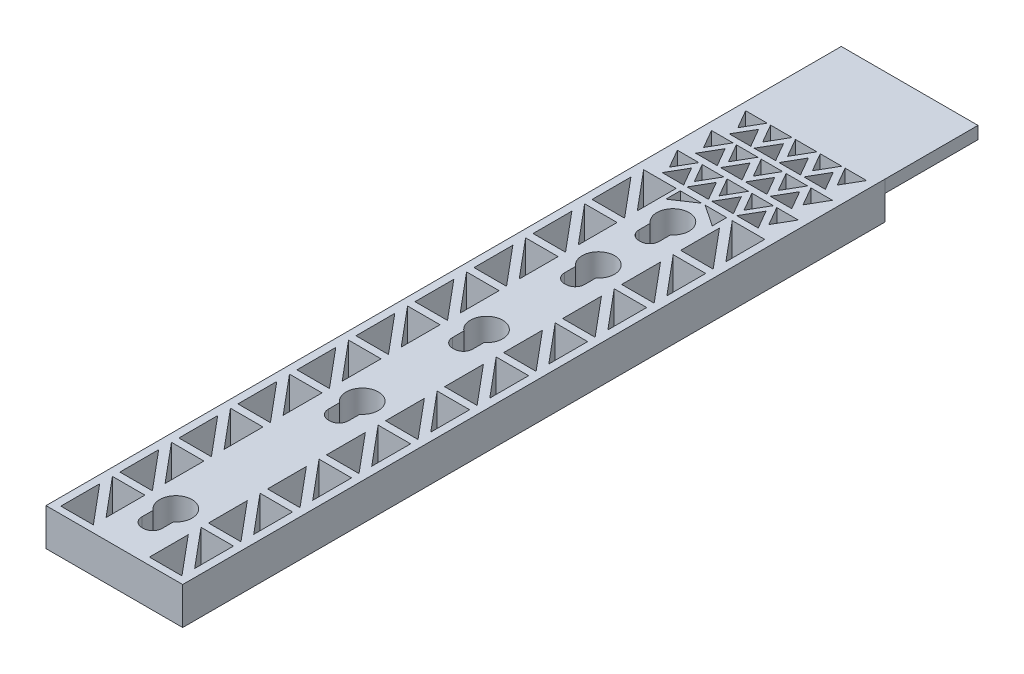
from build123d import *

# Parameters (mm, degrees)
SKETCH23_W             = 22
SKETCH23_H             = 113
SKETCH23_R             = 2.6
BOSS_EXTRUDE3_DEPTH    = 6
SKETCH25_W             = 3.25
SKETCH25_H             = 5.5
CUT_EXTRUDE1_DEPTH     = 15.321988807
FILLET1_R              = 1.5
FILLET2_R              = 1.5
CUT_EXTRUDE7_DEPTH     = 13.794769433
LPATTERN3_COUNT        = 3
LPATTERN3_PITCH        = 4
LPATTERN3_COL_COUNT    = 3
LPATTERN3_COL_PITCH    = 4
LPATTERN4_COUNT        = 3
LPATTERN4_PITCH        = 5.5
LPATTERN4_COPY_1_DEPTH = 13.794769433
LPATTERN4_COPY_2_DEPTH = 13.794769433
LPATTERN4_COPY_3_DEPTH = 13.794769433
LPATTERN4_COPY_4_DEPTH = 13.794769433
LPATTERN4_COPY_5_DEPTH = 13.794769433
LPATTERN4_COPY_6_DEPTH = 13.794769433
LPATTERN4_COPY_7_DEPTH = 13.794769433
LPATTERN4_COPY_8_DEPTH = 13.794769433
CUT_EXTRUDE8_DEPTH     = 13.484872428
LPATTERN5_COUNT        = 4
LPATTERN5_PITCH        = 4
LPATTERN5_COUNT_DIR2   = 3
LPATTERN5_PITCH_DIR2   = 5.4
CUT_EXTRUDE9_DEPTH     = 53.672312212
LPATTERN7_COUNT        = 10
LPATTERN7_PITCH        = 9.5
CUT_EXTRUDE10_DEPTH    = 24.803748702
LPATTERN8_COUNT        = 10
LPATTERN8_PITCH        = 9.5
CUT_EXTRUDE11_DEPTH    = 27.40661391
LPATTERN9_COUNT        = 10
LPATTERN9_PITCH        = 9.5
CUT_EXTRUDE12_DEPTH    = 18.752181215
LPATTERN10_COUNT       = 10
LPATTERN10_PITCH       = 9.5
CUT_EXTRUDE13_DEPTH    = 6
SKETCH42_W             = 22.003595265
SKETCH42_H             = 15
BOSS_EXTRUDE4_DEPTH    = 2
BOSS_EXTRUDE5_DEPTH    = 4


with BuildPart() as part:
    # Sketch23 → Boss-Extrude3 (new body)
    with BuildSketch(Plane(origin=(0, 0, 0), x_dir=(1, 0, 0), z_dir=(0, 1, 0))):
        with Locations((192.096404735, -56.5)):
            Rectangle(SKETCH23_W, SKETCH23_H)
        with Locations((192, -73)):
            Circle(SKETCH23_R, mode=Mode.SUBTRACT)
        with Locations((192, -53)):
            Circle(SKETCH23_R, mode=Mode.SUBTRACT)
        with Locations((192, -35)):
            Circle(SKETCH23_R, mode=Mode.SUBTRACT)
        with Locations((192, -23)):
            Circle(SKETCH23_R, mode=Mode.SUBTRACT)
        with Locations((192, -103)):
            Circle(SKETCH23_R, mode=Mode.SUBTRACT)
    extrude(amount=-BOSS_EXTRUDE3_DEPTH)

    # Sketch25 → Cut-Extrude1 (cut)
    with BuildSketch(Plane(origin=(0, 0, 0), x_dir=(1, 0, 0), z_dir=(0, 1, 0))):
        with Locations((192, -105.6)):
            Rectangle(SKETCH25_W, SKETCH25_H)
        with Locations((192, -75.6)):
            Rectangle(SKETCH25_W, SKETCH25_H)
        with Locations((192, -55.6)):
            Rectangle(SKETCH25_W, SKETCH25_H)
        with Locations((192, -37.6)):
            Rectangle(SKETCH25_W, SKETCH25_H)
        with Locations((192, -25.6)):
            Rectangle(SKETCH25_W, SKETCH25_H)
    extrude(amount=-CUT_EXTRUDE1_DEPTH, mode=Mode.SUBTRACT)

    # Fillet1
    fillet1_edges = [part.edges().sort_by_distance(p)[0] for p in [
        (193.625, -3, 108.35),
        (190.375, -3, 108.35),
        (193.625, -3, 78.35),
        (190.375, -3, 78.35),
        (193.625, -3, 40.35),
        (190.375, -3, 40.35),
        (193.625, -3, 28.35),
        (190.375, -3, 28.35),
    ]]
    fillet(fillet1_edges, radius=FILLET1_R)

    # Fillet2
    fillet2_edges = [part.edges().sort_by_distance(p)[0] for p in [
        (193.625, -3, 58.35),
        (190.375, -3, 58.35),
    ]]
    fillet(fillet2_edges, radius=FILLET2_R)

    # Sketch30 → Cut-Extrude7 (cut)
    with BuildSketch(Plane(origin=(0, 0, 0), x_dir=(1, 0, 0), z_dir=(0, 1, 0))):
        Polygon((192.096404735, -4.654849334), (193.828455542, -1.654849334), (190.364353927, -1.654849334), align=None)
    cut_extrude7 = extrude(amount=-CUT_EXTRUDE7_DEPTH, mode=Mode.SUBTRACT)

    # LPattern3: Cut-Extrude7 ×3
    with Locations(*[(-i * LPATTERN3_PITCH, 0, 0) for i in range(1, LPATTERN3_COUNT)]):
        add(cut_extrude7, mode=Mode.SUBTRACT)

    # LPattern3 col: Cut-Extrude7 ×3
    with Locations(*[(i * LPATTERN3_COL_PITCH, 0, 0) for i in range(1, LPATTERN3_COL_COUNT)]):
        add(cut_extrude7, mode=Mode.SUBTRACT)

    # LPattern4: Cut-Extrude7 ×3
    with Locations(*[(0, 0, i * LPATTERN4_PITCH) for i in range(1, LPATTERN4_COUNT)]):
        add(cut_extrude7, mode=Mode.SUBTRACT)

    # LPattern4 copy 1 sketch → LPattern4 copy 1 (cut)
    with BuildSketch(Plane(origin=(-4, 0, 5.5), x_dir=(1, 0, 0), z_dir=(0, 1, 0))):
        Polygon((192.096404735, -4.654849334), (193.828455542, -1.654849334), (190.364353927, -1.654849334), align=None)
    extrude(amount=-LPATTERN4_COPY_1_DEPTH, mode=Mode.SUBTRACT)

    # LPattern4 copy 2 sketch → LPattern4 copy 2 (cut)
    with BuildSketch(Plane(origin=(-4, 0, 11), x_dir=(1, 0, 0), z_dir=(0, 1, 0))):
        Polygon((192.096404735, -4.654849334), (193.828455542, -1.654849334), (190.364353927, -1.654849334), align=None)
    extrude(amount=-LPATTERN4_COPY_2_DEPTH, mode=Mode.SUBTRACT)

    # LPattern4 copy 3 sketch → LPattern4 copy 3 (cut)
    with BuildSketch(Plane(origin=(-8, 0, 5.5), x_dir=(1, 0, 0), z_dir=(0, 1, 0))):
        Polygon((192.096404735, -4.654849334), (193.828455542, -1.654849334), (190.364353927, -1.654849334), align=None)
    extrude(amount=-LPATTERN4_COPY_3_DEPTH, mode=Mode.SUBTRACT)

    # LPattern4 copy 4 sketch → LPattern4 copy 4 (cut)
    with BuildSketch(Plane(origin=(-8, 0, 11), x_dir=(1, 0, 0), z_dir=(0, 1, 0))):
        Polygon((192.096404735, -4.654849334), (193.828455542, -1.654849334), (190.364353927, -1.654849334), align=None)
    extrude(amount=-LPATTERN4_COPY_4_DEPTH, mode=Mode.SUBTRACT)

    # LPattern4 copy 5 sketch → LPattern4 copy 5 (cut)
    with BuildSketch(Plane(origin=(4, 0, 5.5), x_dir=(1, 0, 0), z_dir=(0, 1, 0))):
        Polygon((192.096404735, -4.654849334), (193.828455542, -1.654849334), (190.364353927, -1.654849334), align=None)
    extrude(amount=-LPATTERN4_COPY_5_DEPTH, mode=Mode.SUBTRACT)

    # LPattern4 copy 6 sketch → LPattern4 copy 6 (cut)
    with BuildSketch(Plane(origin=(4, 0, 11), x_dir=(1, 0, 0), z_dir=(0, 1, 0))):
        Polygon((192.096404735, -4.654849334), (193.828455542, -1.654849334), (190.364353927, -1.654849334), align=None)
    extrude(amount=-LPATTERN4_COPY_6_DEPTH, mode=Mode.SUBTRACT)

    # LPattern4 copy 7 sketch → LPattern4 copy 7 (cut)
    with BuildSketch(Plane(origin=(8, 0, 5.5), x_dir=(1, 0, 0), z_dir=(0, 1, 0))):
        Polygon((192.096404735, -4.654849334), (193.828455542, -1.654849334), (190.364353927, -1.654849334), align=None)
    extrude(amount=-LPATTERN4_COPY_7_DEPTH, mode=Mode.SUBTRACT)

    # LPattern4 copy 8 sketch → LPattern4 copy 8 (cut)
    with BuildSketch(Plane(origin=(8, 0, 11), x_dir=(1, 0, 0), z_dir=(0, 1, 0))):
        Polygon((192.096404735, -4.654849334), (193.828455542, -1.654849334), (190.364353927, -1.654849334), align=None)
    extrude(amount=-LPATTERN4_COPY_8_DEPTH, mode=Mode.SUBTRACT)

    # Sketch31 → Cut-Extrude8 (cut)
    with BuildSketch(Plane(origin=(0, 0, 0), x_dir=(1, 0, 0), z_dir=(0, 1, 0))):
        Polygon((185.996404735, -3.2), (184.264353927, -6.2), (187.728455542, -6.2), align=None)
    cut_extrude8 = extrude(amount=-CUT_EXTRUDE8_DEPTH, mode=Mode.SUBTRACT)

    # LPattern5: Cut-Extrude8 4 × 3
    with Locations(*[(i * LPATTERN5_PITCH, 0, j * LPATTERN5_PITCH_DIR2) for i in range(LPATTERN5_COUNT) for j in range(LPATTERN5_COUNT_DIR2) if (i, j) != (0, 0)]):
        add(cut_extrude8, mode=Mode.SUBTRACT)

    # Sketch33 → Cut-Extrude9 (cut)
    with BuildSketch(Plane(origin=(0, 0, 0), x_dir=(1, 0, 0), z_dir=(0, 1, 0))):
        Polygon((201.826404735, -18.05), (196.596404735, -18.05), (201.826404735, -24.302849063), align=None)
    cut_extrude9 = extrude(amount=-CUT_EXTRUDE9_DEPTH, mode=Mode.SUBTRACT)

    # LPattern7: Cut-Extrude9 ×10
    with Locations(*[(0, 0, i * LPATTERN7_PITCH) for i in range(1, LPATTERN7_COUNT)]):
        add(cut_extrude9, mode=Mode.SUBTRACT)

    # Sketch38 → Cut-Extrude10 (cut)
    with BuildSketch(Plane(origin=(0, 0, 0), x_dir=(1, 0, 0), z_dir=(0, 1, 0))):
        Polygon((187.596404735, -18.08), (182.366404735, -18.08), (187.596404735, -24.332849063), align=None)
    cut_extrude10 = extrude(amount=-CUT_EXTRUDE10_DEPTH, mode=Mode.SUBTRACT)

    # LPattern8: Cut-Extrude10 ×10
    with Locations(*[(0, 0, i * LPATTERN8_PITCH) for i in range(1, LPATTERN8_COUNT)]):
        add(cut_extrude10, mode=Mode.SUBTRACT)

    # Sketch39 → Cut-Extrude11 (cut)
    with BuildSketch(Plane(origin=(0, 0, 0), x_dir=(1, 0, 0), z_dir=(0, 1, 0))):
        Polygon((201.826404735, -26.35), (196.596404735, -20.1), (196.596404735, -26.35), align=None)
    cut_extrude11 = extrude(amount=-CUT_EXTRUDE11_DEPTH, mode=Mode.SUBTRACT)

    # LPattern9: Cut-Extrude11 ×10
    with Locations(*[(0, 0, i * LPATTERN9_PITCH) for i in range(1, LPATTERN9_COUNT)]):
        add(cut_extrude11, mode=Mode.SUBTRACT)

    # Sketch40 → Cut-Extrude12 (cut)
    with BuildSketch(Plane(origin=(0, 0, 0), x_dir=(1, 0, 0), z_dir=(0, 1, 0))):
        Polygon((187.596404735, -26.38), (182.366404735, -20.13), (182.366404735, -26.38), align=None)
    cut_extrude12 = extrude(amount=-CUT_EXTRUDE12_DEPTH, mode=Mode.SUBTRACT)

    # LPattern10: Cut-Extrude12 ×10
    with Locations(*[(0, 0, i * LPATTERN10_PITCH) for i in range(1, LPATTERN10_COUNT)]):
        add(cut_extrude12, mode=Mode.SUBTRACT)

    # Sketch41 → Cut-Extrude13 (cut)
    with BuildSketch(Plane(origin=(0, 0, 0), x_dir=(1, 0, 0), z_dir=(0, 1, 0))):
        Polygon((188.264353927, -18.08), (191.728455542, -18.08), (188.264353927, -20.4), align=None)
        Polygon((195.728455542, -18.08), (192.264353927, -18.08), (195.728455542, -20.4), align=None)
    extrude(amount=-CUT_EXTRUDE13_DEPTH, mode=Mode.SUBTRACT)

    # Sketch42 → Boss-Extrude4 (add)
    with BuildSketch(Plane(origin=(0, 0, 0), x_dir=(1, 0, 0), z_dir=(0, 1, 0))):
        with Locations((192.098202368, 7.5)):
            Rectangle(SKETCH42_W, SKETCH42_H)
    extrude(amount=-BOSS_EXTRUDE4_DEPTH)

    # Sketch48 → Boss-Extrude5 (add)
    with BuildSketch(Plane.XZ.offset(2)):
        Polygon((189.096404735, -12), (195.1, -12), (195.1, -8), (198.1, -8), (198.1, -4), (186.096404735, -4), (186.096404735, -8), (189.096404735, -8), align=None)
    extrude(amount=BOSS_EXTRUDE5_DEPTH)


solid = part.part
